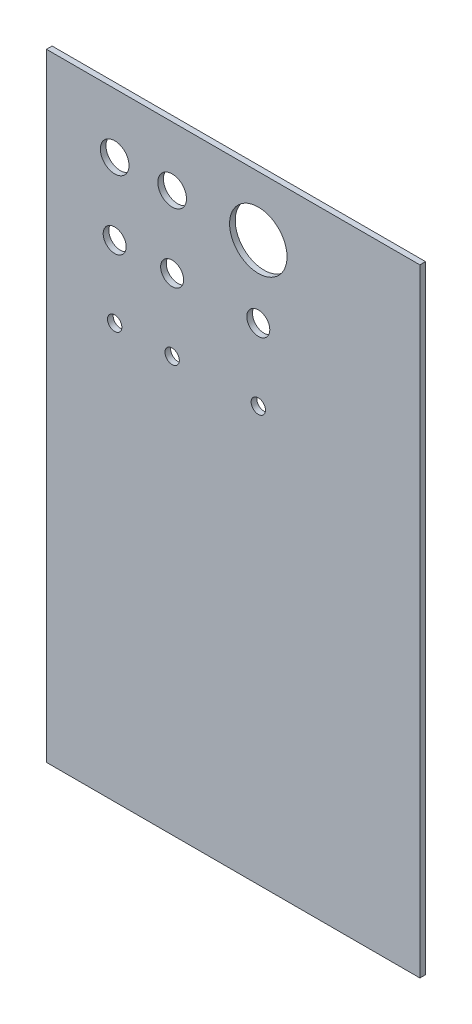
from build123d import *

# Parameters (mm, degrees)
SKETCH1_W           = 3302
SKETCH1_H           = 5461
SKETCH1_R           = 254
SKETCH1_R_2         = 127
SKETCH1_R_3         = 101.6
SKETCH1_R_4         = 63.5
BOSS_EXTRUDE1_DEPTH = 50
SCALE1_SCALE        = 0.04


with BuildPart() as part:
    # Sketch1 → Boss-Extrude1 (new body)
    with BuildSketch(Plane.XY):
        with Locations((1651, 2730.5)):
            Rectangle(SKETCH1_W, SKETCH1_H)
        with Locations((1873.2539878, 4935.236460216)):
            Circle(SKETCH1_R, mode=Mode.SUBTRACT)
        with Locations((603.2539878, 4935.236460216)):
            Circle(SKETCH1_R_2, mode=Mode.SUBTRACT)
        with Locations((603.2539878, 4300.236460216)):
            Circle(SKETCH1_R_3, mode=Mode.SUBTRACT)
        with Locations((603.2539878, 3665.236460216)):
            Circle(SKETCH1_R_4, mode=Mode.SUBTRACT)
        with Locations((1111.2539878, 4935.236460216)):
            Circle(SKETCH1_R_2, mode=Mode.SUBTRACT)
        with Locations((1111.2539878, 4300.236460216)):
            Circle(SKETCH1_R_3, mode=Mode.SUBTRACT)
        with Locations((1111.2539878, 3665.236460216)):
            Circle(SKETCH1_R_4, mode=Mode.SUBTRACT)
        with Locations((1873.2539878, 4300.236460216)):
            Circle(SKETCH1_R_3, mode=Mode.SUBTRACT)
        with Locations((1873.2539878, 3665.236460216)):
            Circle(SKETCH1_R_4, mode=Mode.SUBTRACT)
    extrude(amount=BOSS_EXTRUDE1_DEPTH)


with BuildPart() as part_1:
    # Scale1: scaled about (1656.511334765, 2681.700048918, 25)
    add(part.part.scale(SCALE1_SCALE).moved(Location((1590.250881374, 2574.432046961, 24))))


solid = part_1.part
